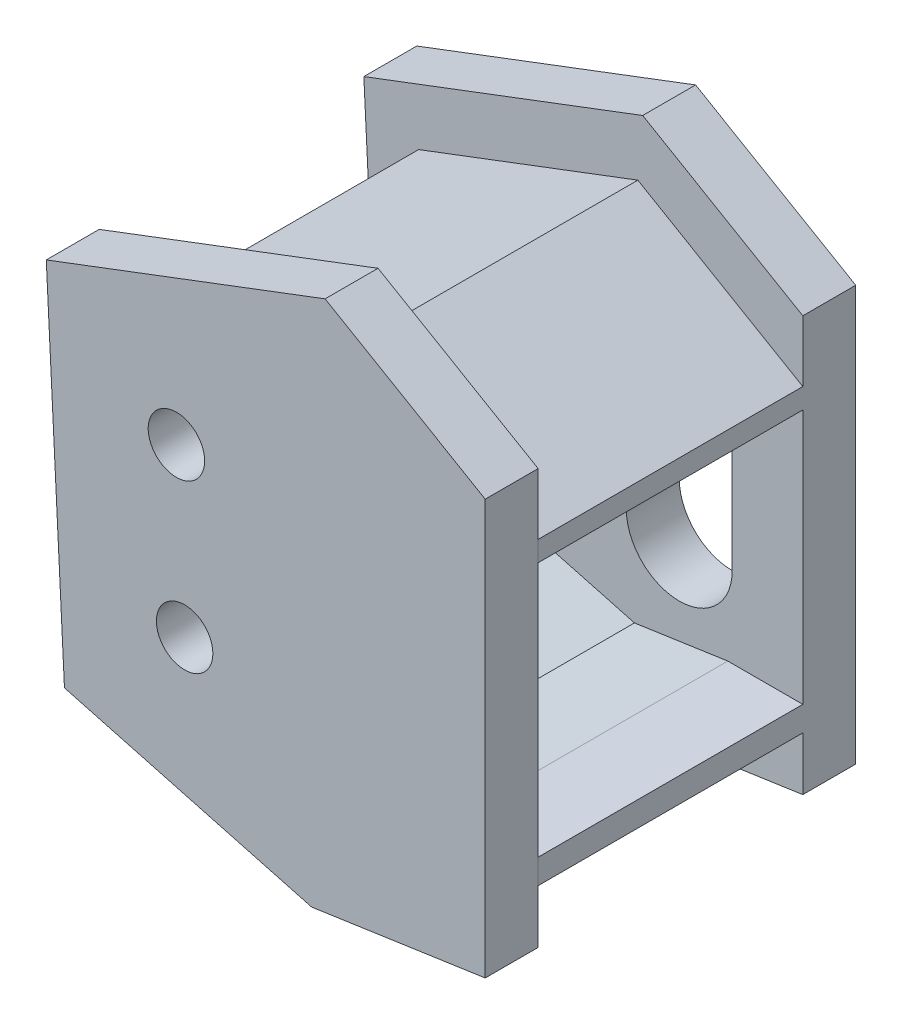
from build123d import *

# Parameters (mm, degrees)
EXTRUDE_1_DEPTH     = 15
EXTRUDE_2_DEPTH     = 3
SKETCH_4_R          = 4
EXTRUDE_3_DEPTH     = 15
EXTRUDE_4_DEPTH     = 3
SKETCH_6_R          = 1.6
CUT_EXTRUDE_1_DEPTH = 3
CUT_EXTRUDE_3_DEPTH = 3
SKETCH_9_R          = 2.15
CUT_EXTRUDE_4_DEPTH = 1
SKETCH_10_R         = 1.8
CUT_EXTRUDE_5_DEPTH = 10


with BuildPart() as part:
    # 草图1 → 凸台-拉伸1 (new body)
    with BuildSketch(Plane.XY):
        Polygon((-1.29e-06, 20.99999997), (-1.203e-06, 19.851325014), (-2.000001203, 19.851325014), (-9.534071771, 24.246698834), (-19.703272348, 20.391514412), (-19.03799413, 7.171769436), (-9.540202332, 4.62684286), (-4.25044565, 5.4), (-1.06e-07, 5.4), (0, 4), (-9.659258026, 2.588191337), (-20.962273217, 5.61682624), (-21.773937734, 21.745413673), (-9.350615446, 26.455144608), align=None)
    extrude(amount=-EXTRUDE_1_DEPTH)

    # 草图2 → 凸台-拉伸2 (add)
    with BuildSketch(Plane(origin=(0, 0, -15), x_dir=(-1, 0, 0), z_dir=(0, 0, -1))):
        Polygon((1.203e-06, 24.473211103), (1.203e-06, 0.968124522), (9.837841565, -0.469785948), (23.848691848, 3.284411448), (24.879935811, 23.776262564), (9.075430959, 29.76781327), align=None)
    extrude(amount=EXTRUDE_2_DEPTH)

    # 草图4 → 凸台-拉伸3 (add)
    with BuildSketch(Plane.XY.offset(-15)):
        with Locations((-17.503272348, 18.391514412)):
            Circle(SKETCH_4_R)
        with Locations((-17.03799413, 9.171769436)):
            Circle(SKETCH_4_R)
    extrude(amount=EXTRUDE_3_DEPTH)

    # 草图8 → 切除-拉伸3 (cut)
    with BuildSketch(Plane(origin=(0, 0, -18), x_dir=(-1, 0, 0), z_dir=(0, 0, -1))):
        with BuildLine():
            Line((10.000001203, 15.968124522), (10.000001203, 9.968124522))
            ThreePointArc((10.000001203, 9.968124522), (7.000001203, 6.968124522), (4.000001203, 9.968124522))
            Line((4.000001203, 9.968124522), (4.000001203, 15.968124522))
            ThreePointArc((4.000001203, 15.968124522), (7.000001203, 18.968124522), (10.000001203, 15.968124522))
        make_face()
    extrude(amount=-CUT_EXTRUDE_3_DEPTH, mode=Mode.SUBTRACT)

    # 草图9 → 切除-拉伸4 (cut)
    with BuildSketch(Plane.XY):
        with Locations((-17.503272348, 18.391514412)):
            Circle(SKETCH_9_R)
        with Locations((-17.03799413, 9.171769436)):
            Circle(SKETCH_9_R)
    extrude(amount=-CUT_EXTRUDE_4_DEPTH, mode=Mode.SUBTRACT)

    # 草图10 → 切除-拉伸5 (cut)
    with BuildSketch(Plane.XY.offset(-1)):
        with Locations((-17.503272348, 18.391514412)):
            Circle(SKETCH_10_R)
        with Locations((-17.03799413, 9.171769436)):
            Circle(SKETCH_10_R)
    extrude(amount=-CUT_EXTRUDE_5_DEPTH, mode=Mode.SUBTRACT)


with BuildPart() as body_2:
    # 草图5 → 凸台-拉伸4 (new body)
    with BuildSketch(Plane.XY):
        Polygon((-1.203e-06, 24.473211103), (-9.075430959, 29.76781327), (-24.879935811, 23.776262564), (-23.848691848, 3.284411448), (-9.837841565, -0.469785948), (-1.203e-06, 0.968124522), align=None)
    extrude(amount=EXTRUDE_4_DEPTH)

    # 草图6 → 切除-拉伸1 (cut)
    with BuildSketch(Plane.XY.offset(3)):
        with Locations((-17.503272348, 18.391514412)):
            Circle(SKETCH_6_R)
        with Locations((-17.03799413, 9.171769436)):
            Circle(SKETCH_6_R)
    extrude(amount=-CUT_EXTRUDE_1_DEPTH, mode=Mode.SUBTRACT)


solid = Compound([part.part, body_2.part])
